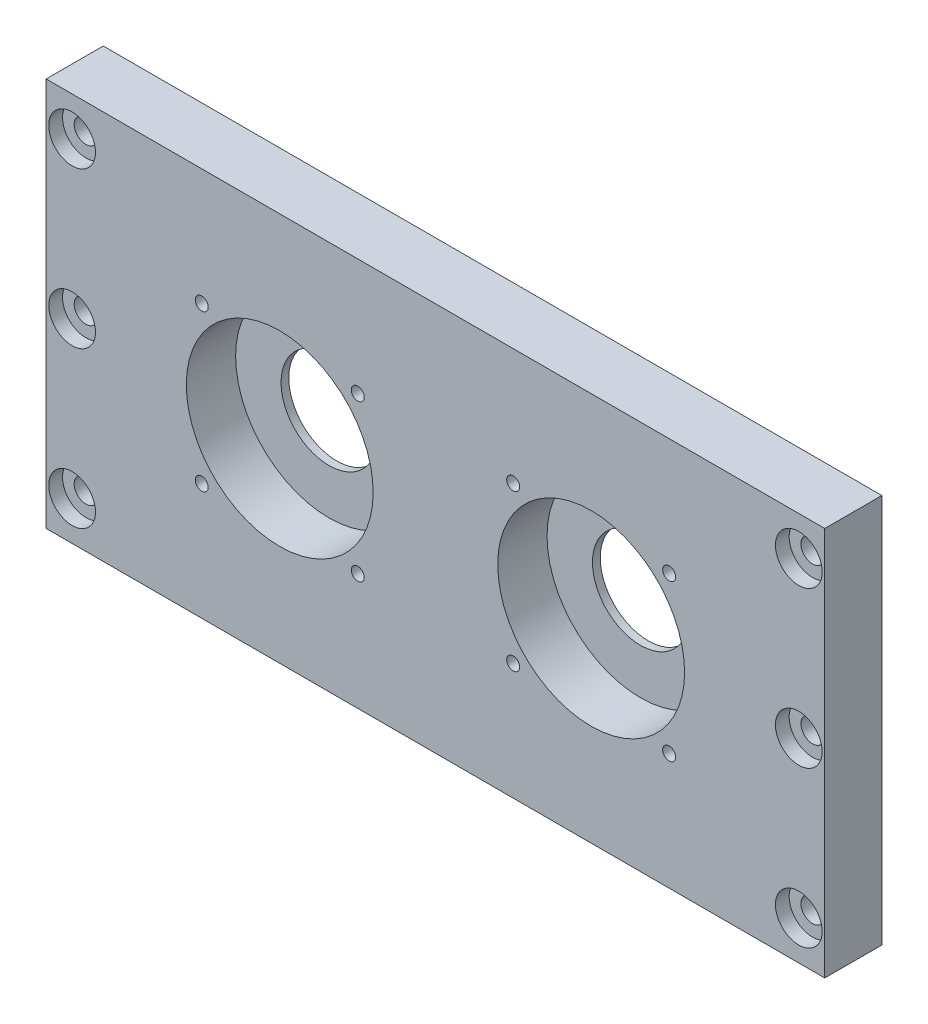
from build123d import *

# Parameters (mm, degrees)
SKETCH1_W                               = 300
SKETCH1_H                               = 150
BOSS_EXTRUDE1_DEPTH                     = 22
CUT_EXTRUDE2_START                      = 22
SKETCH2_R                               = 36
CUT_EXTRUDE2_DEPTH                      = 19
SKETCH4_R                               = 18.5
CUT_EXTRUDE4_DEPTH                      = 3
CBORE_FOR_M8_HEX_HEAD_BOLT1_D           = 9
CBORE_FOR_M8_HEX_HEAD_BOLT1_CBORE_D     = 18.011
CBORE_FOR_M8_HEX_HEAD_BOLT1_CBORE_DEPTH = 5.3
TAP_DRILL_FOR_M6_TAP1_D                 = 5
CIRPATTERN1_COUNT                       = 4
MIRROR2_COPY_1_D                        = 5
MIRROR2_COPY_2_D                        = 5
MIRROR2_COPY_3_D                        = 5


with BuildPart() as part:
    # Sketch1 → Boss-Extrude1 (new body)
    with BuildSketch(Plane.XY):
        Rectangle(SKETCH1_W, SKETCH1_H)
    extrude(amount=BOSS_EXTRUDE1_DEPTH)

    # Sketch2 → Cut-Extrude2 (cut)
    with BuildSketch(Plane.XY.offset(CUT_EXTRUDE2_START)):
        with Locations((-60, 0)):
            Circle(SKETCH2_R)
    cut_extrude2 = extrude(amount=-CUT_EXTRUDE2_DEPTH, mode=Mode.SUBTRACT)

    # Sketch4 → Cut-Extrude4 (cut)
    with BuildSketch(Plane.XY):
        with Locations((-60, 0)):
            Circle(SKETCH4_R)
    cut_extrude4 = extrude(amount=CUT_EXTRUDE4_DEPTH, mode=Mode.SUBTRACT)

    # CBORE for M8 Hex Head Bolt1 (through all)
    with Locations(Plane(origin=(-140, 60, 22), x_dir=(1, 0, 0), z_dir=(0, 0, 1))):
        with Locations((0, 0), (0, -60), (0, -120)):
            cbore_for_m8_hex_head_bolt1 = CounterBoreHole(CBORE_FOR_M8_HEX_HEAD_BOLT1_D / 2, CBORE_FOR_M8_HEX_HEAD_BOLT1_CBORE_D / 2, CBORE_FOR_M8_HEX_HEAD_BOLT1_CBORE_DEPTH)

    # Mirror1: Cut-Extrude2, Cut-Extrude4, CBORE for M8 Hex Head Bolt1 across plane
    add(cut_extrude2.mirror(Plane(origin=(0, 0, 0), x_dir=(0, 0, 1), z_dir=(1, 0, 0))), mode=Mode.SUBTRACT)
    add(cut_extrude4.mirror(Plane(origin=(0, 0, 0), x_dir=(0, 0, 1), z_dir=(1, 0, 0))), mode=Mode.SUBTRACT)
    add(cbore_for_m8_hex_head_bolt1.mirror(Plane(origin=(0, 0, 0), x_dir=(0, 0, 1), z_dir=(1, 0, 0))), mode=Mode.SUBTRACT)

    # Tap Drill for M6 Tap1 (through all)
    with Locations(Plane(origin=(-29.9479618, 30.0520382, 22), x_dir=(1, 0, 0), z_dir=(0, 0, 1))):
        with Locations((0, 0)):
            tap_drill_for_m6_tap1 = Hole(TAP_DRILL_FOR_M6_TAP1_D / 2)

    # CirPattern1: Tap Drill for M6 Tap1 ×4 about axis
    cirpattern1_axis = Axis((-60, 0, 0), (0, 0, 1))
    for i in range(1, CIRPATTERN1_COUNT):
        add(tap_drill_for_m6_tap1.rotate(cirpattern1_axis, i * 360 / CIRPATTERN1_COUNT), mode=Mode.SUBTRACT)

    # Mirror2: Tap Drill for M6 Tap1 across plane
    add(tap_drill_for_m6_tap1.mirror(Plane(origin=(0, 0, 0), x_dir=(0, 0, 1), z_dir=(1, 0, 0))), mode=Mode.SUBTRACT)

    # Mirror2 copy 1 (through all)
    with Locations(Plane(origin=(90.0520382, 30.0520382, 22), x_dir=(0, 1, 0), z_dir=(0, 0, 1))):
        with Locations((0, 0)):
            Hole(MIRROR2_COPY_1_D / 2)

    # Mirror2 copy 2 (through all)
    with Locations(Plane(origin=(90.0520382, -30.0520382, 22), x_dir=(1, 0, 0), z_dir=(0, 0, 1))):
        with Locations((0, 0)):
            Hole(MIRROR2_COPY_2_D / 2)

    # Mirror2 copy 3 (through all)
    with Locations(Plane(origin=(29.9479618, -30.0520382, 22), x_dir=(0, -1, 0), z_dir=(0, 0, 1))):
        with Locations((0, 0)):
            Hole(MIRROR2_COPY_3_D / 2)


solid = part.part
